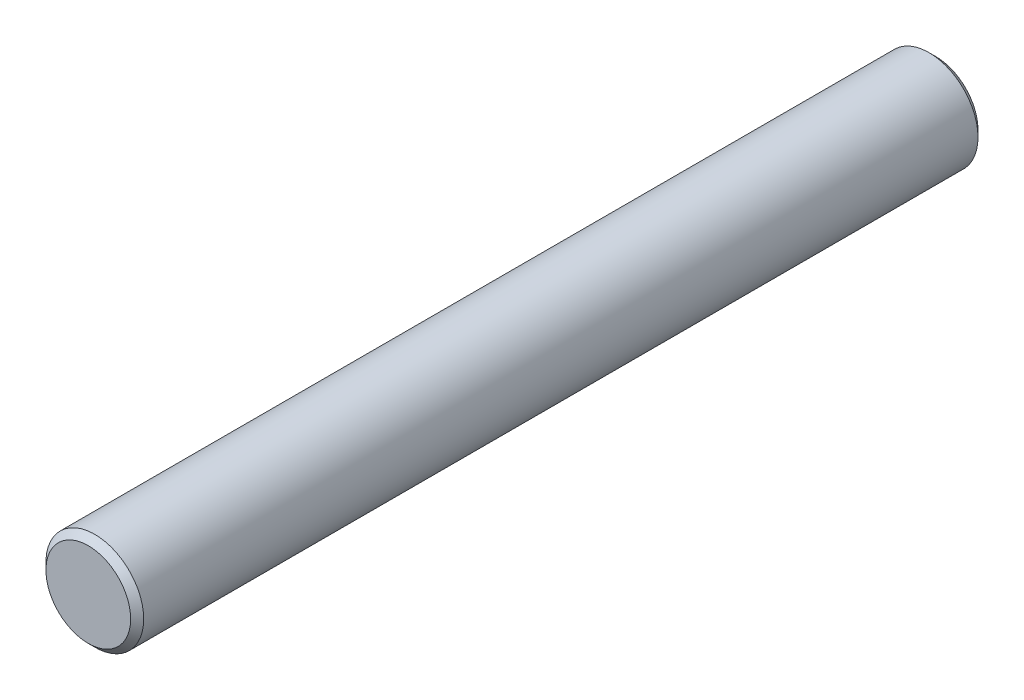
from build123d import *

# Parameters (mm, degrees)
SKETCH1_R           = 0.75
BOSS_EXTRUDE1_DEPTH = 13
CHAMFER1_SIZE       = 0.1


with BuildPart() as part:
    # Sketch1 → Boss-Extrude1 (new body)
    with BuildSketch(Plane.XY):
        Circle(SKETCH1_R)
    extrude(amount=BOSS_EXTRUDE1_DEPTH)

    # Chamfer1
    chamfer1_edges = [part.edges().sort_by_distance(p)[0] for p in [
        (-0.75, 0, 0),
        (-0.75, 0, 13),
    ]]
    chamfer(chamfer1_edges, length=CHAMFER1_SIZE)


solid = part.part
